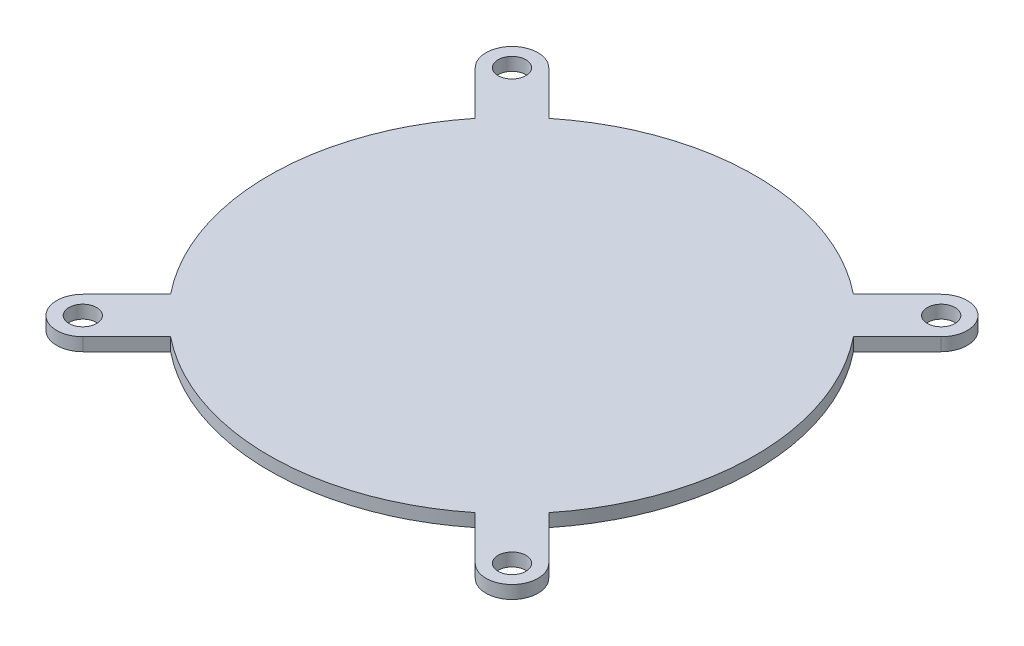
from build123d import *

# Parameters (mm, degrees)
SKETCH1_R                = 1.6
BOSS_EXTRUDE1_DEPTH      = 1.5
FILLET1_R                = 2
SKETCH2_R                = 4
BOSS_EXTRUDE2_DEPTH      = 5
SKETCH5_R                = 13.8
BOSS_EXTRUDE4_DEPTH      = 3
BOSS_EXTRUDE4_DEPTH_BACK = 5
SKETCH6_R                = 10
CUT_EXTRUDE2_DEPTH       = 8
SKETCH3_R                = 1.6
BOSS_EXTRUDE5_DEPTH      = 1.5
SKETCH7_R                = 13.8
SKETCH7_R_2              = 10
BOSS_EXTRUDE6_DEPTH      = 5
SKETCH8_R                = 13.8
CUT_EXTRUDE3_DEPTH       = 3
SKETCH9_R                = 13.8
CUT_EXTRUDE4_DEPTH       = 1
SKETCH10_R               = 28
BOSS_EXTRUDE7_DEPTH      = 1.5


with BuildPart() as part:
    # Sketch1 → Boss-Extrude1 (new body)
    with BuildSketch(Plane(origin=(0, 0, 0), x_dir=(1, 0, 0), z_dir=(0, 1, 0))):
        with BuildLine():
            Line((-23.334523779, -19.091883092), (-20.383302711, -16.140662024))
            ThreePointArc((-20.383302711, -16.140662024), (-26, 0), (-20.383302711, 16.140662024))
            Line((-20.383302711, 16.140662024), (-23.334523779, 19.091883092))
            ThreePointArc((-23.334523779, 19.091883092), (-23.334523779, 23.334523779), (-19.091883092, 23.334523779))
            Line((-19.091883092, 23.334523779), (-16.140662024, 20.383302711))
            ThreePointArc((-16.140662024, 20.383302711), (0, 26), (16.140662024, 20.383302711))
            Line((16.140662024, 20.383302711), (19.091883092, 23.334523779))
            ThreePointArc((19.091883092, 23.334523779), (23.334523779, 23.334523779), (23.334523779, 19.091883092))
            Line((23.334523779, 19.091883092), (20.383302711, 16.140662024))
            ThreePointArc((20.383302711, 16.140662024), (26, 0), (20.383302711, -16.140662024))
            Line((20.383302711, -16.140662024), (23.334523779, -19.091883092))
            ThreePointArc((23.334523779, -19.091883092), (23.334523779, -23.334523779), (19.091883092, -23.334523779))
            Line((19.091883092, -23.334523779), (16.140662024, -20.383302711))
            ThreePointArc((16.140662024, -20.383302711), (0, -26), (-16.140662024, -20.383302711))
            Line((-16.140662024, -20.383302711), (-19.091883092, -23.334523779))
            ThreePointArc((-19.091883092, -23.334523779), (-23.334523779, -23.334523779), (-23.334523779, -19.091883092))
        make_face()
        with Locations((-21.213203436, 21.213203436)):
            Circle(SKETCH1_R, mode=Mode.SUBTRACT)
        with Locations((21.213203436, 21.213203436)):
            Circle(SKETCH1_R, mode=Mode.SUBTRACT)
        with Locations((-21.213203436, -21.213203436)):
            Circle(SKETCH1_R, mode=Mode.SUBTRACT)
        with Locations((21.213203436, -21.213203436)):
            Circle(SKETCH1_R, mode=Mode.SUBTRACT)
    extrude(amount=BOSS_EXTRUDE1_DEPTH)

    # Fillet1
    fillet1_edges = [part.edges().sort_by_distance(p)[0] for p in [
        (-20.383302711, 0.75, -16.140662024),
        (-16.140662024, 0.75, -20.383302711),
        (16.140662024, 0.75, -20.383302711),
        (20.383302711, 0.75, -16.140662024),
        (20.383302711, 0.75, 16.140662024),
        (16.140662024, 0.75, 20.383302711),
        (-16.140662024, 0.75, 20.383302711),
    ]]
    fillet(fillet1_edges, radius=FILLET1_R)

    # Sketch2 → Boss-Extrude2 (add)
    with BuildSketch(Plane(origin=(0, 0, 0), x_dir=(-1, 0, 0), z_dir=(0, -1, 0))):
        Circle(SKETCH2_R)
    extrude(amount=BOSS_EXTRUDE2_DEPTH)

    # Sketch5 → Boss-Extrude4 (add, two sides)
    with BuildSketch(Plane(origin=(0, -5, 0), x_dir=(-1, 0, 0), z_dir=(0, -1, 0))) as boss_extrude4_sk:
        Circle(SKETCH5_R)
    extrude(amount=BOSS_EXTRUDE4_DEPTH)
    extrude(boss_extrude4_sk.sketch, amount=-BOSS_EXTRUDE4_DEPTH_BACK)

    # Sketch6 → Cut-Extrude2 (cut)
    with BuildSketch(Plane(origin=(0, -8, 0), x_dir=(-1, 0, 0), z_dir=(0, -1, 0))):
        Circle(SKETCH6_R)
    extrude(amount=-CUT_EXTRUDE2_DEPTH, mode=Mode.SUBTRACT)

    # Sketch3 → Boss-Extrude5 (add)
    with BuildSketch(Plane(origin=(0, 1.5, 0), x_dir=(1, 0, 0), z_dir=(0, 1, 0))):
        with BuildLine():
            Line((-26.870057685, 22.627416998), (-19.914697313, 15.672056626))
            Line((-19.914697313, 15.672056626), (-15.672056626, 19.914697313))
            Line((-15.672056626, 19.914697313), (-22.627416998, 26.870057685))
            ThreePointArc((-22.627416998, 26.870057685), (-26.870057685, 26.870057685), (-26.870057685, 22.627416998))
        make_face()
        with Locations((-24.748737342, 24.748737342)):
            Circle(SKETCH3_R, mode=Mode.SUBTRACT)
        with BuildLine():
            Line((15.672056626, 19.914697313), (19.914697313, 15.672056626))
            Line((19.914697313, 15.672056626), (26.870057685, 22.627416998))
            ThreePointArc((26.870057685, 22.627416998), (26.870057685, 26.870057685), (22.627416998, 26.870057685))
            Line((22.627416998, 26.870057685), (15.672056626, 19.914697313))
        make_face()
        with Locations((24.748737342, 24.748737342)):
            Circle(SKETCH3_R, mode=Mode.SUBTRACT)
        with BuildLine():
            Line((26.870057685, -22.627416998), (19.914697313, -15.672056626))
            Line((19.914697313, -15.672056626), (15.672056626, -19.914697313))
            Line((15.672056626, -19.914697313), (22.627416998, -26.870057685))
            ThreePointArc((22.627416998, -26.870057685), (26.870057685, -26.870057685), (26.870057685, -22.627416998))
        make_face()
        with Locations((24.748737342, -24.748737342)):
            Circle(SKETCH3_R, mode=Mode.SUBTRACT)
        with BuildLine():
            Line((-15.672056626, -19.914697313), (-19.914697313, -15.672056626))
            Line((-19.914697313, -15.672056626), (-26.870057685, -22.627416998))
            ThreePointArc((-26.870057685, -22.627416998), (-26.870057685, -26.870057685), (-22.627416998, -26.870057685))
            Line((-22.627416998, -26.870057685), (-15.672056626, -19.914697313))
        make_face()
        with Locations((-24.748737342, -24.748737342)):
            Circle(SKETCH3_R, mode=Mode.SUBTRACT)
    extrude(amount=-BOSS_EXTRUDE5_DEPTH)

    # Sketch7 → Boss-Extrude6 (add)
    with BuildSketch(Plane(origin=(0, -8, 0), x_dir=(-1, 0, 0), z_dir=(0, -1, 0))):
        Circle(SKETCH7_R)
        Circle(SKETCH7_R_2, mode=Mode.SUBTRACT)
    extrude(amount=BOSS_EXTRUDE6_DEPTH)

    # Sketch8 → Cut-Extrude3 (cut)
    with BuildSketch(Plane(origin=(0, -13, 0), x_dir=(-1, 0, 0), z_dir=(0, -1, 0))):
        Circle(SKETCH8_R)
    extrude(amount=-CUT_EXTRUDE3_DEPTH, mode=Mode.SUBTRACT)

    # Sketch9 → Cut-Extrude4 (cut)
    with BuildSketch(Plane(origin=(0, -10, 0), x_dir=(-1, 0, 0), z_dir=(0, -1, 0))):
        Circle(SKETCH9_R)
    extrude(amount=-CUT_EXTRUDE4_DEPTH, mode=Mode.SUBTRACT)

    # Sketch10 → Boss-Extrude7 (add)
    with BuildSketch(Plane(origin=(0, 1.5, 0), x_dir=(1, 0, 0), z_dir=(0, 1, 0))):
        Circle(SKETCH10_R)
    extrude(amount=-BOSS_EXTRUDE7_DEPTH)


solid = part.part
